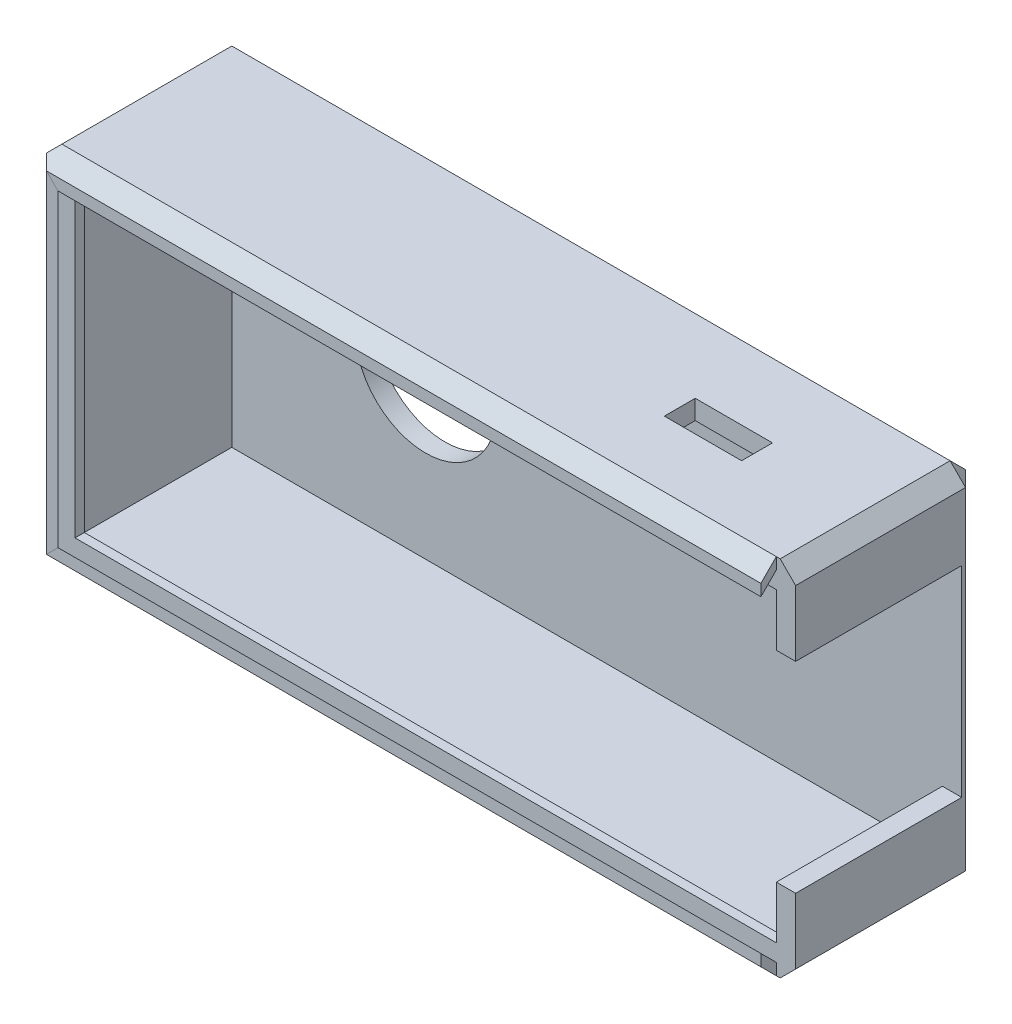
from build123d import *

# Parameters (mm, degrees)
SKETCH1_W               = 48.5
SKETCH1_H               = 23.5
BOSS_EXTRUDE1_DEPTH     = 12
SHELL1_T                = -1.25
SKETCH2_R               = 4.55
CUT_EXTRUDE1_DEPTH      = 11.75
CUT_EXTRUDE1_DEPTH_BACK = 2.25
SKETCH3_W               = 10.75
SKETCH3_H               = 13
CUT_EXTRUDE2_DEPTH      = 3
CHAMFER1_SIZE           = 1
CUT_EXTRUDE3_REACH      = 25.5
SKETCH5_W               = 5
SKETCH5_H               = 2
SKETCH6_W               = 0.6
SKETCH6_H               = 0.6


with BuildPart() as part:
    # Sketch1 → Boss-Extrude1 (new body)
    with BuildSketch(Plane.XY):
        Rectangle(SKETCH1_W, SKETCH1_H)
    extrude(amount=BOSS_EXTRUDE1_DEPTH)

    # Shell1
    shell1_openings = [part.faces().sort_by_distance(p)[0] for p in [
        (0, 0, 12),
    ]]
    offset(amount=SHELL1_T, openings=shell1_openings, kind=Kind.INTERSECTION)

    # Sketch2 → Cut-Extrude1 (cut, two sides)
    with BuildSketch(Plane.XY.offset(1.25)) as cut_extrude1_sk:
        with Locations((-10.45, 0)):
            Circle(SKETCH2_R)
    extrude(amount=CUT_EXTRUDE1_DEPTH, mode=Mode.SUBTRACT)
    extrude(cut_extrude1_sk.sketch, amount=-CUT_EXTRUDE1_DEPTH_BACK, mode=Mode.SUBTRACT)

    # Sketch3 → Cut-Extrude2 (cut)
    with BuildSketch(Plane(origin=(24.25, 0, 0), x_dir=(0, 0, -1), z_dir=(1, 0, 0))):
        with Locations((-6.625, 0)):
            Rectangle(SKETCH3_W, SKETCH3_H)
    extrude(amount=-CUT_EXTRUDE2_DEPTH, mode=Mode.SUBTRACT)

    # Sweep2: sweep along a curve in space
    with BuildLine() as sweep2_path:
        Line((23, -10.5, 12), (-23, -10.5, 12))
        Line((-23, -10.5, 12), (-23, 10.5, 12))
        Line((-23, 10.5, 12), (23, 10.5, 12))
    # Sketch4 → Sweep2 (sweep)
    with BuildSketch(Plane(origin=(23, 0, 0), x_dir=(0, 0, -1), z_dir=(1, 0, 0))):
        Polygon((-12, -11.75), (-13, -10.75), (-13, -10), (-12, -11), align=None)
    sweep(path=sweep2_path.line, transition=Transition.RIGHT)

    # Chamfer1
    chamfer1_edges = [part.edges().sort_by_distance(p)[0] for p in [
        (0, -11.75, 0),
        (-24.25, 0, 0),
        (0, 11.75, 0),
        (24.25, 0, 0),
        (24.25, -11.75, 6),
        (-24.25, -11.75, 6),
        (-24.25, 11.75, 6),
        (24.25, 11.75, 6),
    ]]
    chamfer(chamfer1_edges, length=CHAMFER1_SIZE)

    # Sketch5 → Cut-Extrude3 (cut, up to next)
    with BuildSketch(Plane(origin=(0, 11.75, 0), x_dir=(1, 0, 0), z_dir=(0, 1, 0)), mode=Mode.PRIVATE) as cut_extrude3_sk1:
        with Locations((14, -6.75)):
            Rectangle(SKETCH5_W, SKETCH5_H)
    cut_extrude3_tool1 = extrude(cut_extrude3_sk1.sketch, amount=-CUT_EXTRUDE3_REACH, mode=Mode.PRIVATE) & part.part
    add(cut_extrude3_tool1.solids().sort_by_distance((14, 11.75, 6.75))[0], mode=Mode.SUBTRACT)

    # Sweep3: sweep along a curve in space
    with BuildLine() as sweep3_path:
        Line((23, -10.5, 12), (-23, -10.5, 12))
        Line((-23, -10.5, 12), (-23, 10.5, 12))
        Line((-23, 10.5, 12), (23, 10.5, 12))
    # Sketch6 → Sweep3 (sweep)
    with BuildSketch(Plane.ZY.offset(-23)):
        with Locations((11.7, -10.2)):
            Rectangle(SKETCH6_W, SKETCH6_H)
    sweep(path=sweep3_path.line, transition=Transition.RIGHT)


solid = part.part
